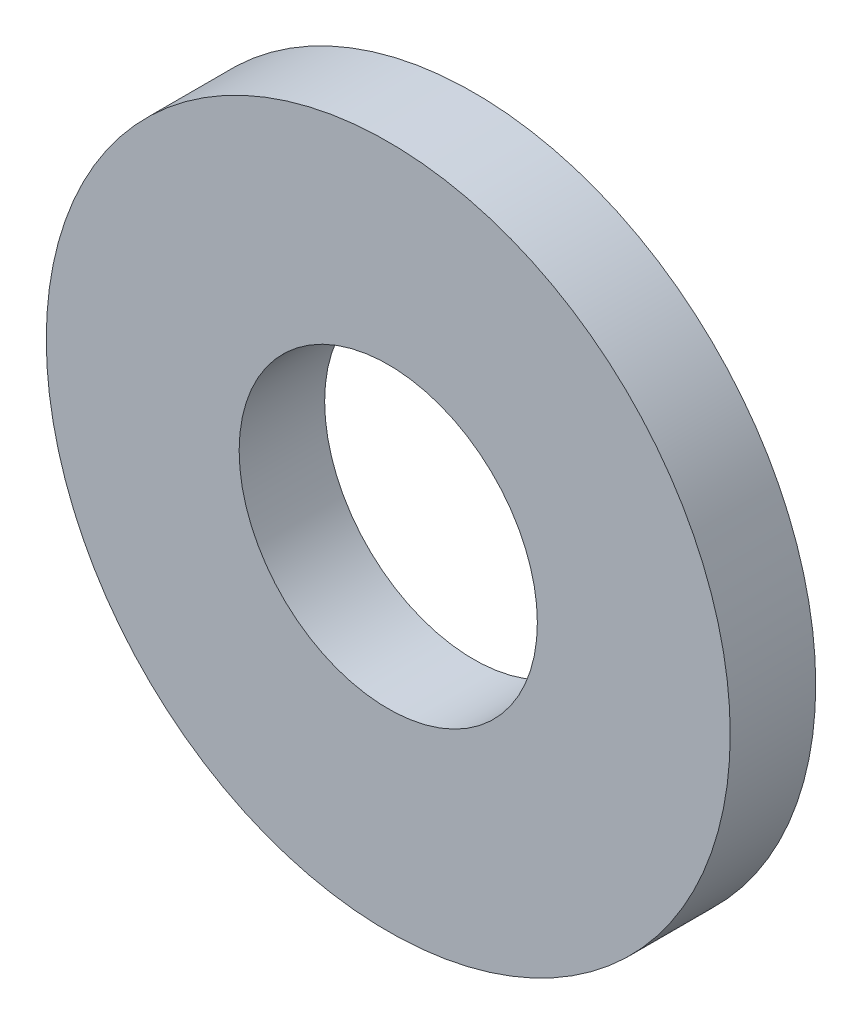
from build123d import *

# Parameters (mm, degrees)
SKETCH1_R      = 6.35
SKETCH1_R_2    = 2.7686
EXTRUDE1_DEPTH = 0.79375


with BuildPart() as part:
    # Sketch1 → Extrude1 (new body, symmetric)
    with BuildSketch(Plane.XY):
        Circle(SKETCH1_R)
        Circle(SKETCH1_R_2, mode=Mode.SUBTRACT)
    extrude(amount=EXTRUDE1_DEPTH, both=True)


solid = part.part
